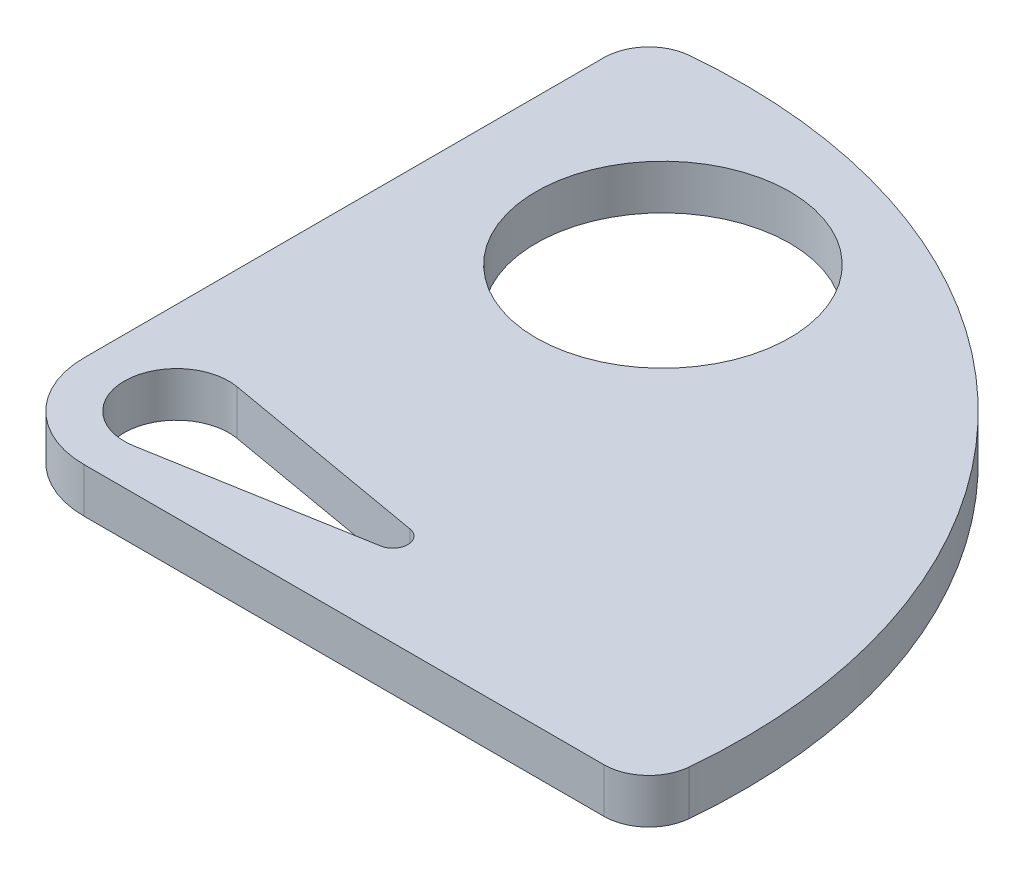
from build123d import *

# Parameters (mm, degrees)
SKETCH8_R           = 1.5
SKETCH8_R_2         = 8.5
BOSS_EXTRUDE3_DEPTH = 3
CUT_EXTRUDE3_DEPTH  = 4
FILLET1_R           = 3


with BuildPart() as part:
    # Sketch8 → Boss-Extrude3 (new body)
    with BuildSketch(Plane(origin=(0, 0, 0), x_dir=(1, 0, 0), z_dir=(0, 1, 0))):
        with BuildLine():
            Line((-12, -51.2), (25.490798871, -51.2))
            ThreePointArc((25.490798871, -51.2), (14.870057685, -18.129942315), (-18.2, -7.509201129))
            Line((-18.2, -7.509201129), (-18.2, -45))
            ThreePointArc((-18.2, -45), (-16.384062043, -49.384062043), (-12, -51.2))
        make_face()
        with Locations((-12, -45)):
            Circle(SKETCH8_R, mode=Mode.SUBTRACT)
        with Locations((-4.2, -20.197580763)):
            Circle(SKETCH8_R_2, mode=Mode.SUBTRACT)
    extrude(amount=BOSS_EXTRUDE3_DEPTH)

    # Sketch10 → Cut-Extrude3 (cut, through all)
    with BuildSketch(Plane(origin=(0, 0, 0), x_dir=(1, 0, 0), z_dir=(0, 1, 0))):
        with BuildLine():
            Line((-11.396551724, -41.552413862), (2.672413793, -44.014975389))
            ThreePointArc((2.672413793, -44.014975389), (3.5, -45), (2.672413793, -45.985024611))
            Line((2.672413793, -45.985024611), (-11.396551724, -48.447586138))
            ThreePointArc((-11.396551724, -48.447586138), (-15.5, -45), (-11.396551724, -41.552413862))
        make_face()
    extrude(amount=CUT_EXTRUDE3_DEPTH, mode=Mode.SUBTRACT)

    # Fillet1
    fillet1_edges = [part.edges().sort_by_distance(p)[0] for p in [
        (-18.2, 1.5, 7.509201129),
        (25.490798871, 1.5, 51.2),
    ]]
    fillet(fillet1_edges, radius=FILLET1_R)


solid = part.part
